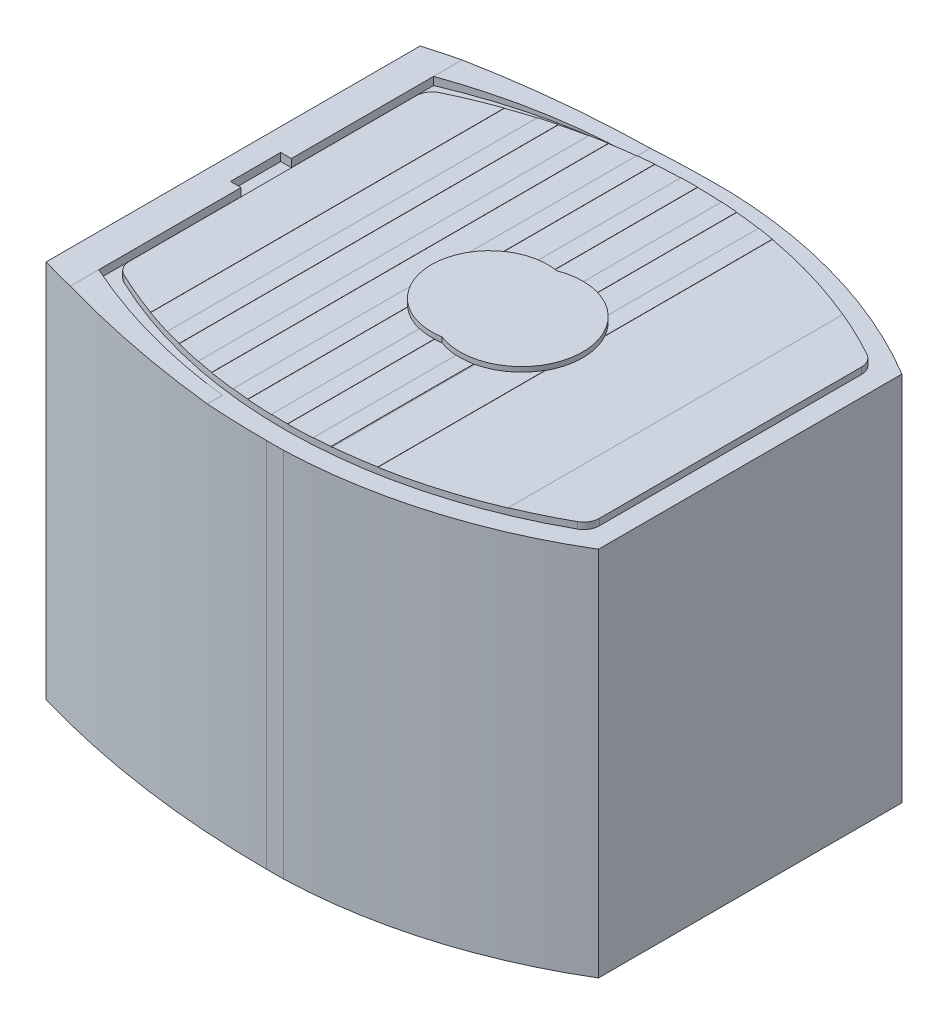
from build123d import *

# Parameters (mm, degrees)
BOSS_EXTRUDE1_DEPTH      = 40
CUT_EXTRUDE1_DEPTH       = 40
CUT_EXTRUDE1_DEPTH_BACK  = 40
CUT_EXTRUDE2_DEPTH       = 40
BOSS_EXTRUDE2_DEPTH      = 0.6223
CUT_EXTRUDE3_DEPTH       = 0.0254
CUT_EXTRUDE4_DEPTH       = 2.032
BOSS_EXTRUDE3_DEPTH      = 0.464
BOSS_EXTRUDE3_DEPTH_BACK = 0.464


with BuildPart() as part:
    # Sketch1 → Boss-Extrude1 (new body)
    with BuildSketch(Plane(origin=(0, -30.021892368, 0), x_dir=(-1, 0, 0), z_dir=(0, -1, 0))):
        with BuildLine():
            Line((-83.1596, 21.651358884), (-84.762120236, 21.651358884))
            ThreePointArc((-84.762120236, 21.651358884), (-96.885117924, 19.694671586), (-108.1278, 14.755258884))
            Line((-108.1278, 14.755258884), (-108.1278, -14.378541116))
            ThreePointArc((-108.1278, -14.378541116), (-96.885117924, -19.317953818), (-84.762120236, -21.274641116))
            Line((-84.762120236, -21.274641116), (-83.1596, -21.274641116))
            ThreePointArc((-83.1596, -21.274641116), (-70.690971885, -20.397039146), (-58.4708, -17.769441116))
            Line((-58.4708, -17.769441116), (-58.4708, 18.146158884))
            ThreePointArc((-58.4708, 18.146158884), (-70.690971885, 20.773756915), (-83.1596, 21.651358884))
        make_face()
    extrude(amount=-BOSS_EXTRUDE1_DEPTH)

    # Sketch2 → Cut-Extrude1 (cut, two sides)
    with BuildSketch(Plane.XY) as cut_extrude1_sk:
        Polygon((54.820843696, 15.118469848), (54.820843696, 6.401707632), (61.6458, 6.401707632), (77.2668, 5.639707632), (110.448229866, 5.639707632), (110.448229866, 15.118469848), align=None)
    extrude(amount=CUT_EXTRUDE1_DEPTH, mode=Mode.SUBTRACT)
    extrude(cut_extrude1_sk.sketch, amount=-CUT_EXTRUDE1_DEPTH_BACK, mode=Mode.SUBTRACT)

    # Sketch3 → Cut-Extrude2 (cut)
    with BuildSketch(Plane(origin=(0, 5.639707632, 0), x_dir=(1, 0, 0), z_dir=(0, 1, 0))):
        with BuildLine():
            Line((60.6298, -2.224641116), (61.6458, -2.224641116))
            Line((61.6458, -2.224641116), (61.6458, -15.889841116))
            ThreePointArc((61.6458, -15.889841116), (69.299882493, -18.411140892), (77.2668, -19.623641116))
            Line((77.2668, -19.623641116), (77.2668, -24.484863345))
            Line((77.2668, -24.484863345), (116.145527093, -24.484863345))
            Line((116.145527093, -24.484863345), (116.145527093, 24.141945465))
            Line((116.145527093, 24.141945465), (77.2668, 24.141945465))
            Line((77.2668, 24.141945465), (77.2668, 20.000358884))
            ThreePointArc((77.2668, 20.000358884), (69.299882493, 18.78785866), (61.6458, 16.266558884))
            Line((61.6458, 16.266558884), (61.6458, 2.601358884))
            Line((61.6458, 2.601358884), (60.6298, 2.601358884))
            Line((60.6298, 2.601358884), (60.6298, -2.224641116))
        make_face()
    extrude(amount=CUT_EXTRUDE2_DEPTH, mode=Mode.SUBTRACT)

    # Sketch4 → Boss-Extrude2 (add)
    with BuildSketch(Plane(origin=(0, 5.639707632, 0), x_dir=(1, 0, 0), z_dir=(0, 1, 0))):
        with BuildLine():
            Line((62.2808, 13.97160372), (62.2808, -13.595028424))
            ThreePointArc((62.2808, -13.595028424), (62.515232291, -14.407180579), (63.146405148, -14.969470936))
            ThreePointArc((63.146405148, -14.969470936), (84.443626018, -19.477271857), (105.437261458, -13.718873038))
            ThreePointArc((105.437261458, -13.718873038), (106.011810141, -13.159417141), (106.2228, -12.385737382))
            Line((106.2228, -12.385737382), (106.2228, 12.76231749))
            ThreePointArc((106.2228, 12.76231749), (106.011758355, 13.536085129), (105.437082995, 14.095551986))
            ThreePointArc((105.437082995, 14.095551986), (84.443582525, 19.852401671), (63.146588971, 15.346134273))
            ThreePointArc((63.146588971, 15.346134273), (62.515286602, 14.783842106), (62.2808, 13.97160372))
        make_face()
    extrude(amount=BOSS_EXTRUDE2_DEPTH)

    # Sketch5 → Cut-Extrude3 (cut)
    with BuildSketch(Plane(origin=(0, 6.236607632, 0), x_dir=(1, 0, 0), z_dir=(0, 1, 0))):
        Polygon((60.8798, -1.974641116), (61.8958, -1.974641116), (61.8958, -15.724128062), (70.725222183, -18.261597014), (77.5168, -19.389388124), (77.5168, -26.279232644), (112.598613265, -26.279232644), (112.598613265, 26.642797699), (77.5168, 26.642797699), (77.5168, 19.766105893), (68.79799987, 18.208824767), (61.8958, 16.100845831), (61.8958, 2.351358884), (60.8798, 2.351358884), align=None)
        with BuildLine():
            Line((106.2228, -12.385737382), (106.2228, 12.76231749))
            ThreePointArc((106.2228, 12.76231749), (106.011758355, 13.536085129), (105.437082995, 14.095551986))
            ThreePointArc((105.437082995, 14.095551986), (103.230284294, 15.241015763), (100.965, 16.26597178))
            Line((100.965, 16.26597178), (100.965, -15.890015871))
            ThreePointArc((100.965, -15.890015871), (103.230393421, -14.864721653), (105.437261458, -13.718873038))
            ThreePointArc((105.437261458, -13.718873038), (106.011810141, -13.159417141), (106.2228, -12.385737382))
        make_face(mode=Mode.SUBTRACT)
        with BuildLine():
            Line((87.4776, -5.556736292), (87.4776, -19.287368321))
            ThreePointArc((87.4776, -19.287368321), (89.400866501, -19.062397708), (91.313, -18.756928734))
            Line((91.313, -18.756928734), (91.313, 19.132183186))
            ThreePointArc((91.313, 19.132183186), (90.526712944, 19.267736149), (89.7382, 19.389675799))
            Line((89.7382, 19.389675799), (89.7382, 4.870687927))
            Line((89.7382, 4.870687927), (87.4776, -5.556736292))
        make_face(mode=Mode.SUBTRACT)
        with BuildLine():
            Line((87.3506, -19.299351408), (87.3506, 19.674500659))
            ThreePointArc((87.3506, 19.674500659), (86.56371005, 19.740853373), (85.7758, 19.79373275))
            Line((85.7758, 19.79373275), (85.7758, -19.418600488))
            ThreePointArc((85.7758, -19.418600488), (86.563710251, -19.365714311), (87.3506, -19.299351408))
        make_face(mode=Mode.SUBTRACT)
        with BuildLine():
            Line((83.3882, -19.496401918), (83.3882, 19.871534346))
            ThreePointArc((83.3882, 19.871534346), (82.60073032, 19.870084861), (81.8134, 19.855199773))
            Line((81.8134, 19.855199773), (81.8134, -19.480050269))
            ThreePointArc((81.8134, -19.480050269), (82.600730229, -19.49494558), (83.3882, -19.496401918))
        make_face(mode=Mode.SUBTRACT)
        with BuildLine():
            Line((79.4258, -19.352519351), (79.4258, 19.727720695))
            ThreePointArc((79.4258, 19.727720695), (78.637747467, 19.658336413), (77.851, 19.575454588))
            Line((77.851, 19.575454588), (77.851, -19.200201536))
            ThreePointArc((77.851, -19.200201536), (78.63774708, -19.283110929), (79.4258, -19.352519351))
        make_face(mode=Mode.SUBTRACT)
        with BuildLine():
            Line((73.8886, 18.948166135), (73.8886, -18.57271762))
            ThreePointArc((73.8886, -18.57271762), (74.674734009, -18.725427281), (75.4634, -18.864469988))
            Line((75.4634, -18.864469988), (75.4634, 19.239829185))
            ThreePointArc((75.4634, 19.239829185), (74.674734726, 19.100829354), (73.8886, 18.948166135))
        make_face(mode=Mode.SUBTRACT)
        with BuildLine():
            Line((69.9262, 17.958552472), (69.9262, -17.58280399))
            ThreePointArc((69.9262, -17.58280399), (70.711659458, -17.808862859), (71.501, -18.020972927))
            Line((71.501, -18.020972927), (71.501, 18.396588518))
            ThreePointArc((71.501, 18.396588518), (70.711660575, 18.184542996), (69.9262, 17.958552472))
        make_face(mode=Mode.SUBTRACT)
        with BuildLine():
            Line((67.5386, -16.801329329), (67.5386, 17.177317791))
            ThreePointArc((67.5386, 17.177317791), (65.318978341, 16.31836829), (63.146588971, 15.346134273))
            ThreePointArc((63.146588971, 15.346134273), (62.515286602, 14.783842106), (62.2808, 13.97160372))
            Line((62.2808, 13.97160372), (62.2808, -13.595028424))
            ThreePointArc((62.2808, -13.595028424), (62.515232309, -14.407180609), (63.146405211, -14.969470967))
            ThreePointArc((63.146405211, -14.969470967), (65.318869691, -15.942064117), (67.5386, -16.801329329))
        make_face(mode=Mode.SUBTRACT)
    extrude(amount=CUT_EXTRUDE3_DEPTH, mode=Mode.SUBTRACT)

    # Sketch6 → Cut-Extrude4 (cut)
    with BuildSketch(Plane(origin=(0, -30.021892368, 0), x_dir=(-1, 0, 0), z_dir=(0, -1, 0))):
        with BuildLine():
            Line((-103.354005387, 3.220690187), (-102.196585301, 2.30003668))
            Line((-102.196585301, 2.30003668), (-103.552849915, 1.710316042))
            Line((-103.552849915, 1.710316042), (-102.319593922, 0.894041707))
            Line((-102.319593922, 0.894041707), (-103.6193, 0.188358884))
            Line((-103.6193, 0.188358884), (-102.319593922, -0.517323938))
            Line((-102.319593922, -0.517323938), (-103.552849915, -1.333598274))
            Line((-103.552849915, -1.333598274), (-102.196585301, -1.923318911))
            Line((-102.196585301, -1.923318911), (-103.354005387, -2.843972418))
            ThreePointArc((-103.354005387, -2.843972418), (-68.6943, 0.188358884), (-103.354005387, 3.220690187))
        make_face()
    extrude(amount=-CUT_EXTRUDE4_DEPTH, mode=Mode.SUBTRACT)

    # Sketch7 → Boss-Extrude3 (add, two sides)
    with BuildSketch(Plane(origin=(0, 6.262007632, 0), x_dir=(1, 0, 0), z_dir=(0, 1, 0))) as boss_extrude3_sk:
        with BuildLine():
            ThreePointArc((84.054570469, -5.319023636), (92.051766601, 0.188358884), (84.054570469, 5.695741404))
            ThreePointArc((84.054570469, 5.695741404), (77.5208, 0.188358884), (84.054570469, -5.319023636))
        make_face()
    extrude(amount=BOSS_EXTRUDE3_DEPTH)
    extrude(boss_extrude3_sk.sketch, amount=-BOSS_EXTRUDE3_DEPTH_BACK)


solid = part.part
